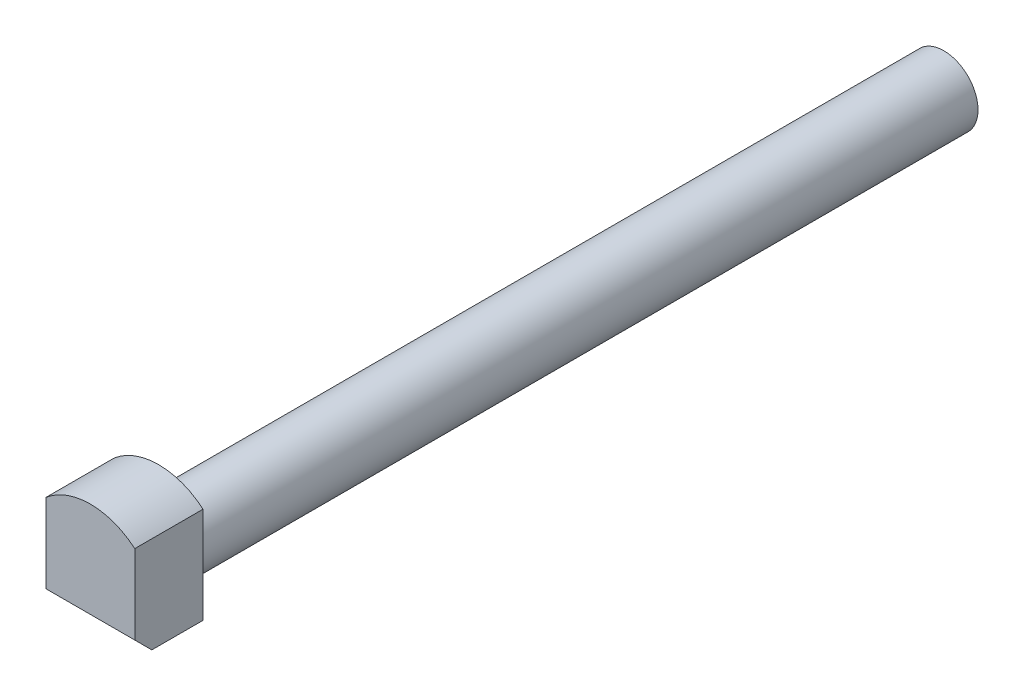
from build123d import *

# Parameters (mm, degrees)
ESQUISSE2_R             = 1
BOSS_EXTRU_1_DEPTH      = 16.5
BOSS_EXTRU_1_DEPTH_BACK = 11
ESQUISSE3_R             = 2
BOSS_EXTRU_2_DEPTH      = 2
ESQUISSE4_OUTSIDE_W     = 12.008
ESQUISSE4_OUTSIDE_H     = 12.008
ENL_V_MAT_EXTRU_1_DEPTH = 30.5
CHANFREIN1_SIZE         = 0.5
ESQUISSE6_R             = 1
ENL_V_MAT_EXTRU_2_DEPTH = 4.5


with BuildPart() as part:
    # Esquisse2 → Boss.-Extru.1 (new body, two sides)
    with BuildSketch(Plane.XY) as boss_extru_1_sk:
        with Locations((0, 1.35)):
            Circle(ESQUISSE2_R)
    extrude(amount=BOSS_EXTRU_1_DEPTH)
    extrude(boss_extru_1_sk.sketch, amount=-BOSS_EXTRU_1_DEPTH_BACK)

    # Esquisse3 → Boss.-Extru.2 (add)
    with BuildSketch(Plane.XY.offset(16.5)):
        with Locations((0, 1.35)):
            Circle(ESQUISSE3_R)
    extrude(amount=BOSS_EXTRU_2_DEPTH)

    # Esquisse4 outside → Enlèv. mat.-Extru.1 (cut, through all)
    with BuildSketch(Plane.XY.offset(18.5)):
        with Locations((0, 1.35)):
            Rectangle(ESQUISSE4_OUTSIDE_W, ESQUISSE4_OUTSIDE_H)
        with BuildLine():
            Line((-1.3, 2.869868415), (-1.3, 0.05))
            Line((-1.3, 0.05), (1.3, 0.05))
            Line((1.3, 0.05), (1.3, 2.869868415))
            ThreePointArc((1.3, 2.869868415), (0, 3.35), (-1.3, 2.869868415))
        make_face(mode=Mode.SUBTRACT)
    extrude(amount=-ENL_V_MAT_EXTRU_1_DEPTH, mode=Mode.SUBTRACT)

    # Chanfrein1
    chanfrein1_edges = [part.edges().sort_by_distance(p)[0] for p in [
        (0, 0.05, 18.5),
    ]]
    chamfer(chanfrein1_edges, length=CHANFREIN1_SIZE)

    # Esquisse6 → Enlèv. mat.-Extru.2 (cut)
    with BuildSketch(Plane(origin=(0, 0, -11), x_dir=(-1, 0, 0), z_dir=(0, 0, -1))):
        with Locations((0, 1.35)):
            Circle(ESQUISSE6_R)
    extrude(amount=-ENL_V_MAT_EXTRU_2_DEPTH, mode=Mode.SUBTRACT)


solid = part.part
